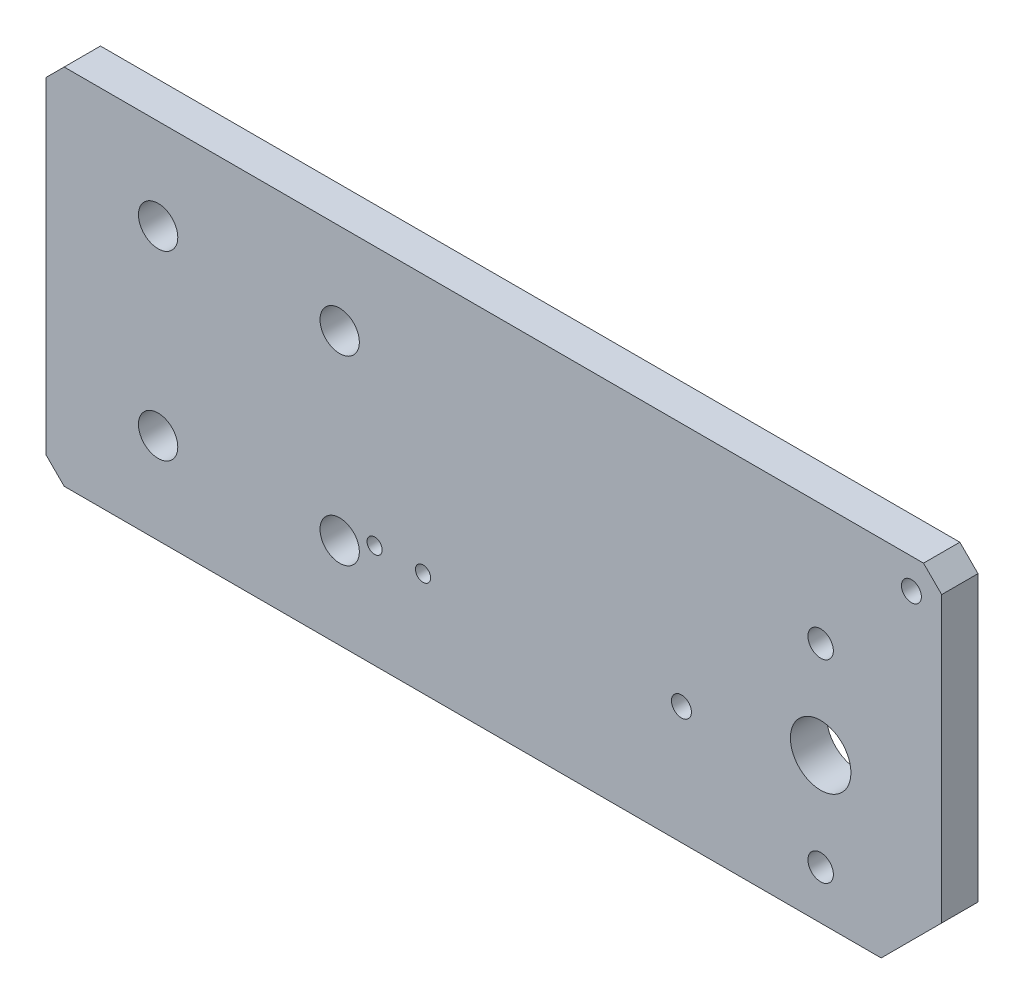
from build123d import *

# Parameters (mm, degrees)
SKETCH1_W             = 148
SKETCH1_H             = 60
SKETCH1_R             = 3.25
SKETCH1_R_2           = 5
BOSS_EXTRUDE1_DEPTH   = 6
M5X0_8_TAPPED_HOLE1_D = 4.2
M4X0_7_TAPPED_HOLE1_D = 3.3
M3X0_5_TAPPED_HOLE1_D = 2.5
CHAMFER1_SIZE         = 10
CHAMFER2_SIZE         = 3


with BuildPart() as part:
    # Sketch1 → Boss-Extrude1 (new body)
    with BuildSketch(Plane.XY):
        with Locations((20.481223922, -2.599443672)):
            Rectangle(SKETCH1_W, SKETCH1_H)
        with Locations((-34.993045897, 12.400556328)):
            Circle(SKETCH1_R, mode=Mode.SUBTRACT)
        with Locations((-4.993045897, 12.400556328)):
            Circle(SKETCH1_R, mode=Mode.SUBTRACT)
        with Locations((-34.993045897, -17.599443672)):
            Circle(SKETCH1_R, mode=Mode.SUBTRACT)
        with Locations((-4.993045897, -17.599443672)):
            Circle(SKETCH1_R, mode=Mode.SUBTRACT)
        with Locations((74.481223922, -8.599443672)):
            Circle(SKETCH1_R_2, mode=Mode.SUBTRACT)
    extrude(amount=BOSS_EXTRUDE1_DEPTH)

    # M5x0.8 Tapped Hole1 (through all)
    with Locations(Plane.XY.offset(6)):
        with Locations((74.481223922, 7.400556328), (74.481223922, -24.599443672)):
            Hole(M5X0_8_TAPPED_HOLE1_D / 2)

    # M4x0.7 Tapped Hole1 (through all)
    with Locations(Plane.XY.offset(6)):
        with Locations((89.481223922, 22.400556328), (51.481223922, -13.099443672)):
            Hole(M4X0_7_TAPPED_HOLE1_D / 2)

    # M3x0.5 Tapped Hole1 (through all)
    with Locations(Plane.XY.offset(6)):
        with Locations((0.781223922, -15.449443672), (8.781223922, -15.449443672)):
            Hole(M3X0_5_TAPPED_HOLE1_D / 2)

    # Chamfer1
    chamfer1_edges = [part.edges().sort_by_distance(p)[0] for p in [
        (94.481223922, -32.599443672, 3),
    ]]
    chamfer(chamfer1_edges, length=CHAMFER1_SIZE)

    # Chamfer2
    chamfer2_edges = [part.edges().sort_by_distance(p)[0] for p in [
        (-53.518776078, 27.400556328, 3),
        (94.481223922, 27.400556328, 3),
        (-53.518776078, -32.599443672, 3),
    ]]
    chamfer(chamfer2_edges, length=CHAMFER2_SIZE)


solid = part.part
